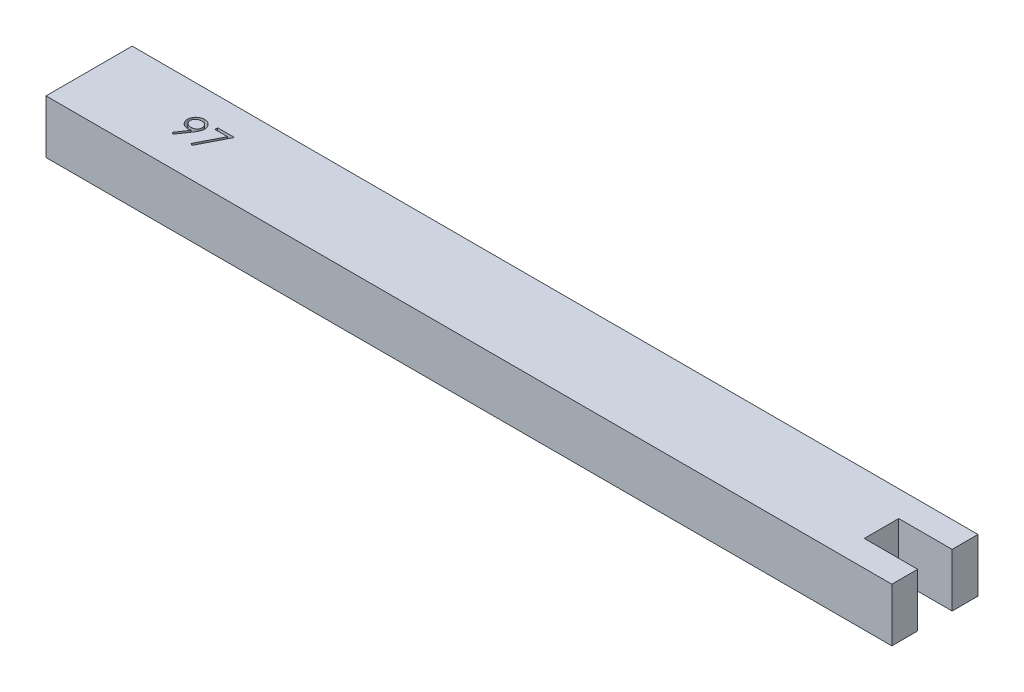
from build123d import *

# Parameters (mm, degrees)
BOSS_EXTRUDE1_DEPTH = 6.2
CUT_EXTRUDE1_DEPTH  = 1


with BuildPart() as part:
    # Sketch1 → Boss-Extrude1 (new body)
    with BuildSketch(Plane(origin=(0, 0, 0), x_dir=(1, 0, 0), z_dir=(0, 1, 0))):
        Polygon((0, 0), (91.95, 0), (98.15, 0), (98.15, 3), (93.712314791, 3), (91.95, 3), (91.95, 7), (93.712314791, 7), (98.15, 7), (98.15, 10), (91.95, 10), (0, 10), align=None)
    extrude(amount=BOSS_EXTRUDE1_DEPTH)

    # Sketch2 → Cut-Extrude1 (cut)
    with BuildSketch(Plane(origin=(0, 6.2, 0), x_dir=(1, 0, 0), z_dir=(0, 1, 0))):
        with BuildLine():
            Line((11.210257143, 3.497319833), (10.982562832, 3.655688223))
            Line((10.982562832, 3.655688223), (11.8653553, 4.94616799))
            add(Edge.make_bspline(
                [(11.8653553, 4.94616799), (11.809030133, 4.939279997), (11.698122738, 4.925717154), (11.586419796, 4.923225546), (11.531446045, 4.92199932)],
                knots=[0, 0, 0, 0, 0.000170115, 0.000334967, 0.000334967, 0.000334967, 0.000334967], degree=3))
            add(Edge.make_bspline(
                [(11.531446045, 4.92199932), (11.498115759, 4.922853011), (11.432691322, 4.924528731), (11.336505466, 4.937810943), (11.244080707, 4.958267131), (11.155662077, 4.988791358), (11.070917241, 5.026726448), (10.990031201, 5.073768168), (10.913112843, 5.129109589), (10.840988264, 5.192458089), (10.775391186, 5.262016036), (10.716950052, 5.335635798), (10.668380597, 5.414172571), (10.62803398, 5.496024271), (10.59743564, 5.582367353), (10.575153909, 5.672219309), (10.561435774, 5.76620987), (10.559803737, 5.830186239), (10.558975092, 5.862669392)],
                knots=[0, 0, 0, 0, 9.9954e-05, 0.000196201, 0.000290782, 0.000383503, 0.000476303, 0.000568919, 0.000663705, 0.000760153, 0.000856434, 0.000950205, 0.001041624, 0.001132931, 0.001223461, 0.001315861, 0.001410305, 0.001507717, 0.001507717, 0.001507717, 0.001507717], degree=3))
            add(Edge.make_bspline(
                [(10.558975092, 5.862669392), (10.560548472, 5.907090956), (10.563636698, 5.994281474), (10.588491067, 6.121674964), (10.629367232, 6.242131329), (10.686361545, 6.355333862), (10.758148043, 6.459654147), (10.844425121, 6.553641957), (10.944668003, 6.635960503), (11.05659312, 6.706721344), (11.17756336, 6.763630949), (11.304262786, 6.8055766), (11.435720595, 6.83024975), (11.524772696, 6.833502638), (11.569607103, 6.835140346)],
                knots=[0, 0, 0, 0, 0.000133185, 0.000261414, 0.000387724, 0.00051373, 0.000640399, 0.00076644, 0.000895188, 0.001028407, 0.001162697, 0.001295241, 0.001427846, 0.0015623, 0.0015623, 0.0015623, 0.0015623], degree=3))
            add(Edge.make_bspline(
                [(11.569607103, 6.835140346), (11.613593027, 6.833480127), (11.700505066, 6.83019969), (11.828311522, 6.806174946), (11.950722301, 6.765683107), (12.067058825, 6.709726396), (12.174772434, 6.639585287), (12.271633349, 6.556006112), (12.355431159, 6.458936812), (12.426028537, 6.35072511), (12.482697788, 6.234459349), (12.523584787, 6.113098219), (12.548754046, 5.987514522), (12.551925714, 5.902429535), (12.553526374, 5.859489304)],
                knots=[0, 0, 0, 0, 0.000131915, 0.000260652, 0.000388569, 0.000517718, 0.000646848, 0.000773094, 0.000900237, 0.001030248, 0.001159674, 0.001287189, 0.001413545, 0.001542287, 0.001542287, 0.001542287, 0.001542287], degree=3))
            add(Edge.make_bspline(
                [(12.553526374, 5.859489304), (12.552457389, 5.826157458), (12.55028922, 5.758552146), (12.535106998, 5.65583605), (12.50932583, 5.551105292), (12.480068932, 5.462457844), (12.451827608, 5.38924375), (12.425247296, 5.33141196), (12.395754128, 5.270541528), (12.361356391, 5.207270729), (12.324379165, 5.140793001), (12.282596821, 5.071775108), (12.236962481, 5.000124436), (12.204459807, 4.95182172), (12.187816238, 4.927087461)],
                knots=[0, 0, 0, 0, 9.9984e-05, 0.000202793, 0.000310776, 0.000423207, 0.000482616, 0.000546097, 0.000614079, 0.0006855, 0.000762103, 0.000842274, 0.000927493, 0.001016928, 0.001016928, 0.001016928, 0.001016928], degree=3))
            Line((12.187816238, 4.927087461), (11.210257143, 3.497319833))
        make_face()
        with BuildLine():
            add(Edge.make_bspline(
                [(11.584235509, 5.247640346), (11.609484936, 5.248330123), (11.658636986, 5.249672883), (11.730643536, 5.257845553), (11.798610492, 5.27233624), (11.862719411, 5.293127693), (11.923613101, 5.318216243), (11.980324341, 5.350158545), (12.032900595, 5.388273635), (12.081693929, 5.431099863), (12.1250227, 5.478680036), (12.163615307, 5.528479554), (12.196418107, 5.580717021), (12.22232908, 5.636046624), (12.243632945, 5.69312152), (12.258344999, 5.752860828), (12.266495072, 5.814953306), (12.26788443, 5.857134231), (12.268590477, 5.878569833)],
                knots=[0, 0, 0, 0, 7.5753e-05, 0.000147465, 0.000217073, 0.000283852, 0.000349411, 0.000414338, 0.000478589, 0.000543925, 0.000608743, 0.000671332, 0.000732749, 0.000793345, 0.000854313, 0.000915245, 0.00097749, 0.001041807, 0.001041807, 0.001041807, 0.001041807], degree=3))
            add(Edge.make_bspline(
                [(12.268590477, 5.878569833), (12.267982991, 5.900014387), (12.266785866, 5.94227351), (12.257181673, 6.004457916), (12.240285935, 6.064051089), (12.217615995, 6.121379279), (12.187752636, 6.175971473), (12.151917331, 6.228513071), (12.109342895, 6.27867093), (12.060354853, 6.325265401), (12.007527794, 6.368216709), (11.951230054, 6.40612265), (11.891925666, 6.437891878), (11.829976436, 6.464107372), (11.765253291, 6.484565054), (11.69779453, 6.499276521), (11.62725927, 6.507415184), (11.579379103, 6.50879576), (11.554978698, 6.50949932)],
                knots=[0, 0, 0, 0, 6.4316e-05, 0.000126743, 0.000188161, 0.000249812, 0.000311283, 0.000374438, 0.00044032, 0.000508243, 0.00057698, 0.000644365, 0.000711521, 0.0007785, 0.000845884, 0.000914871, 0.00098532, 0.001058531, 0.001058531, 0.001058531, 0.001058531], degree=3))
            add(Edge.make_bspline(
                [(11.554978698, 6.50949932), (11.530790501, 6.508794623), (11.48333346, 6.507412013), (11.413425258, 6.499291991), (11.346422627, 6.484466116), (11.281887014, 6.464116848), (11.219939625, 6.437889922), (11.160638034, 6.406120985), (11.104327126, 6.368225435), (11.051550715, 6.325231606), (11.002476171, 6.278887812), (10.960633727, 6.228293345), (10.924716411, 6.175998805), (10.894894087, 6.121372015), (10.872213232, 6.064053027), (10.855320416, 6.004457391), (10.845715438, 5.942273646), (10.84451842, 5.900014433), (10.843910989, 5.878569833)],
                knots=[0, 0, 0, 0, 7.2576e-05, 0.000142393, 0.000210758, 0.000278143, 0.000345121, 0.000412278, 0.000479663, 0.0005484, 0.000616323, 0.000681795, 0.00074495, 0.000806421, 0.000868072, 0.00092949, 0.000991917, 0.001056233, 0.001056233, 0.001056233, 0.001056233], degree=3))
            add(Edge.make_bspline(
                [(10.843910989, 5.878569833), (10.844460651, 5.857117539), (10.845544684, 5.814809687), (10.856002036, 5.752646459), (10.87349019, 5.693057883), (10.896912066, 5.635464556), (10.927756365, 5.580426514), (10.965605856, 5.528204693), (11.009970173, 5.478207106), (11.060256265, 5.431210563), (11.115290954, 5.388073947), (11.174070859, 5.350399958), (11.235584069, 5.31858424), (11.300047119, 5.293055985), (11.366982288, 5.272543976), (11.436991157, 5.25787226), (11.509842201, 5.249751275), (11.559199827, 5.24835074), (11.584235509, 5.247640346)],
                knots=[0, 0, 0, 0, 6.4316e-05, 0.000126844, 0.000188436, 0.000250326, 0.000312966, 0.000377217, 0.000443451, 0.000513196, 0.000583426, 0.000652939, 0.000722346, 0.000790847, 0.000860662, 0.000932137, 0.001005113, 0.00108023, 0.00108023, 0.00108023, 0.00108023], degree=3))
        make_face(mode=Mode.SUBTRACT)
        Polygon((13.164103297, 6.75373009), (15.117949451, 6.75373009), (13.449039195, 3.497319833), (13.202900372, 3.632791588), (14.635848089, 6.428089064), (13.164103297, 6.428089064), align=None)
    extrude(amount=-CUT_EXTRUDE1_DEPTH, mode=Mode.SUBTRACT)


solid = part.part
